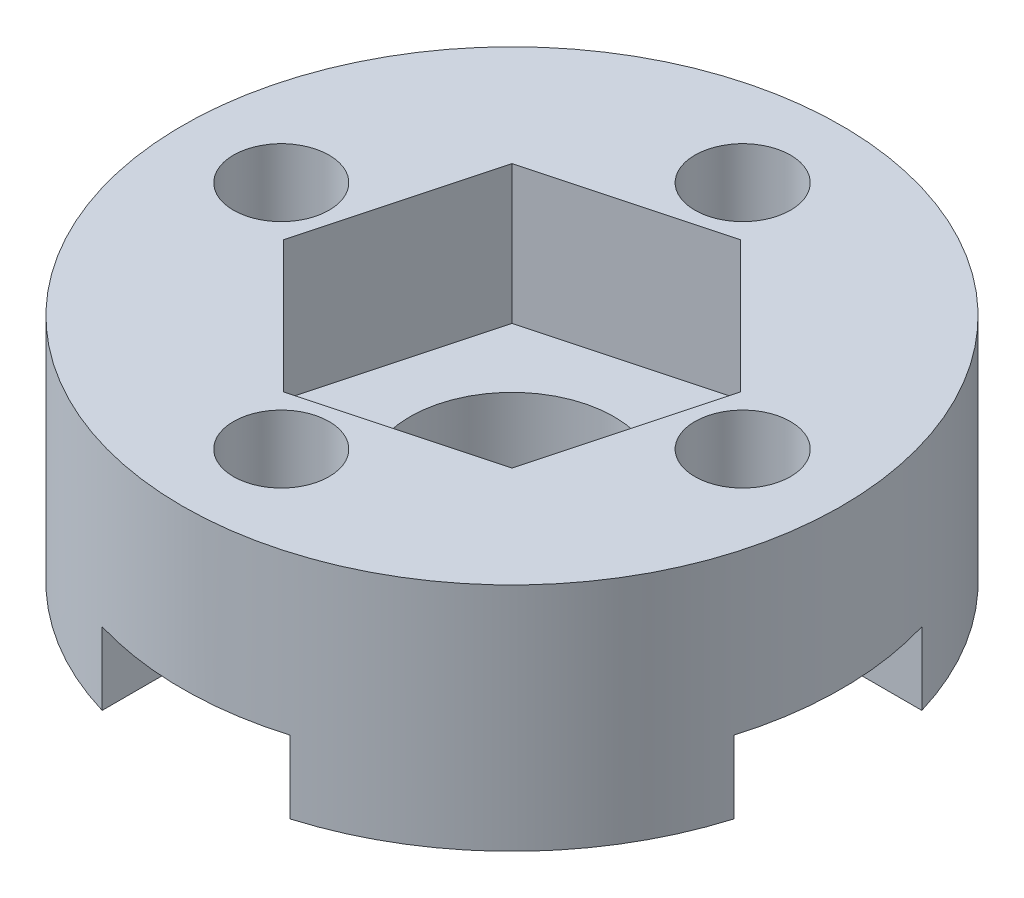
from build123d import *

# Parameters (mm, degrees)
SKETCH1_R           = 10
SKETCH1_R_2         = 3.1
SKETCH1_R_3         = 1.45
BOSS_EXTRUDE1_DEPTH = 7
SKETCH8_R           = 5.25
SKETCH8_R_2         = 3.1
BOSS_EXTRUDE4_DEPTH = 1
CUT_EXTRUDE1_DEPTH  = 3.2
CUT_EXTRUDE2_DEPTH  = 4.2


with BuildPart() as part:
    # Sketch1 → Boss-Extrude1 (new body)
    with BuildSketch(Plane(origin=(0, 0, 0), x_dir=(1, 0, 0), z_dir=(0, 1, 0))):
        Circle(SKETCH1_R)
        Circle(SKETCH1_R_2, mode=Mode.SUBTRACT)
        with Locations((0, 7)):
            Circle(SKETCH1_R_3, mode=Mode.SUBTRACT)
        with Locations((7, 0)):
            Circle(SKETCH1_R_3, mode=Mode.SUBTRACT)
        with Locations((0, -7)):
            Circle(SKETCH1_R_3, mode=Mode.SUBTRACT)
        with Locations((-7, 0)):
            Circle(SKETCH1_R_3, mode=Mode.SUBTRACT)
    extrude(amount=BOSS_EXTRUDE1_DEPTH)

    # Sketch8 → Boss-Extrude4 (add)
    with BuildSketch(Plane.XZ):
        Circle(SKETCH8_R)
        Circle(SKETCH8_R_2, mode=Mode.SUBTRACT)
    extrude(amount=BOSS_EXTRUDE4_DEPTH)

    # Sketch9 → Cut-Extrude1 (cut)
    with BuildSketch(Plane.XZ.offset(1)):
        with BuildLine():
            Line((-7, 2.85), (-9.585275166, 2.85))
            ThreePointArc((-9.585275166, 2.85), (-10, 0), (-9.585275166, -2.85))
            Line((-9.585275166, -2.85), (-7, -2.85))
            ThreePointArc((-7, -2.85), (-5.845254282, -2.605582915), (-4.888571429, -1.914254264))
            ThreePointArc((-4.888571429, -1.914254264), (-5.25, 0), (-4.888571429, 1.914254264))
            ThreePointArc((-4.888571429, 1.914254264), (-5.845254282, 2.605582915), (-7, 2.85))
        make_face()
        with BuildLine():
            Line((-2.85, 9.585275166), (-2.85, 7))
            ThreePointArc((-2.85, 7), (-2.605582915, 5.845254282), (-1.914254264, 4.888571429))
            ThreePointArc((-1.914254264, 4.888571429), (0, 5.25), (1.914254264, 4.888571429))
            ThreePointArc((1.914254264, 4.888571429), (2.605582915, 5.845254282), (2.85, 7))
            Line((2.85, 7), (2.85, 9.585275166))
            ThreePointArc((2.85, 9.585275166), (0, 10), (-2.85, 9.585275166))
        make_face()
        with BuildLine():
            ThreePointArc((10, 0), (9.895775656, 1.440008393), (9.585275166, 2.85))
            Line((9.585275166, 2.85), (7, 2.85))
            ThreePointArc((7, 2.85), (5.845254282, 2.605582915), (4.888571429, 1.914254264))
            ThreePointArc((4.888571429, 1.914254264), (5.158851616, 0.974037987), (5.25, 0))
            ThreePointArc((5.25, 0), (5.158851616, -0.974037987), (4.888571429, -1.914254264))
            ThreePointArc((4.888571429, -1.914254264), (5.845254282, -2.605582915), (7, -2.85))
            Line((7, -2.85), (9.585275166, -2.85))
            ThreePointArc((9.585275166, -2.85), (9.895775656, -1.440008393), (10, 0))
        make_face()
        with BuildLine():
            Line((-2.85, -7), (-2.85, -9.585275166))
            ThreePointArc((-2.85, -9.585275166), (0, -10), (2.85, -9.585275166))
            Line((2.85, -9.585275166), (2.85, -7))
            ThreePointArc((2.85, -7), (2.605582915, -5.845254282), (1.914254264, -4.888571429))
            ThreePointArc((1.914254264, -4.888571429), (0, -5.25), (-1.914254264, -4.888571429))
            ThreePointArc((-1.914254264, -4.888571429), (-2.605582915, -5.845254282), (-2.85, -7))
        make_face()
        with BuildLine():
            ThreePointArc((-4.888571429, -1.914254264), (-4.15, 0), (-4.888571429, 1.914254264))
            ThreePointArc((-4.888571429, 1.914254264), (-5.25, 0), (-4.888571429, -1.914254264))
        make_face()
        with BuildLine():
            ThreePointArc((1.914254264, 4.888571429), (0, 5.25), (-1.914254264, 4.888571429))
            ThreePointArc((-1.914254264, 4.888571429), (0, 4.15), (1.914254264, 4.888571429))
        make_face()
        with BuildLine():
            ThreePointArc((5.25, 0), (5.158851616, 0.974037987), (4.888571429, 1.914254264))
            ThreePointArc((4.888571429, 1.914254264), (4.15, 0), (4.888571429, -1.914254264))
            ThreePointArc((4.888571429, -1.914254264), (5.158851616, -0.974037987), (5.25, 0))
        make_face()
        with BuildLine():
            ThreePointArc((1.914254264, -4.888571429), (0, -4.15), (-1.914254264, -4.888571429))
            ThreePointArc((-1.914254264, -4.888571429), (0, -5.25), (1.914254264, -4.888571429))
        make_face()
    extrude(amount=-CUT_EXTRUDE1_DEPTH, mode=Mode.SUBTRACT)

    # Sketch10 → Cut-Extrude2 (cut)
    with BuildSketch(Plane(origin=(0, 7, 0), x_dir=(1, 0, 0), z_dir=(0, 1, 0))):
        Polygon((1.464406605, 5.465239851), (-4.000833247, 4.000833247), (-5.465239851, -1.464406605), (-1.464406605, -5.465239851), (4.000833247, -4.000833247), (5.465239851, 1.464406605), align=None)
    extrude(amount=-CUT_EXTRUDE2_DEPTH, mode=Mode.SUBTRACT)


solid = part.part
